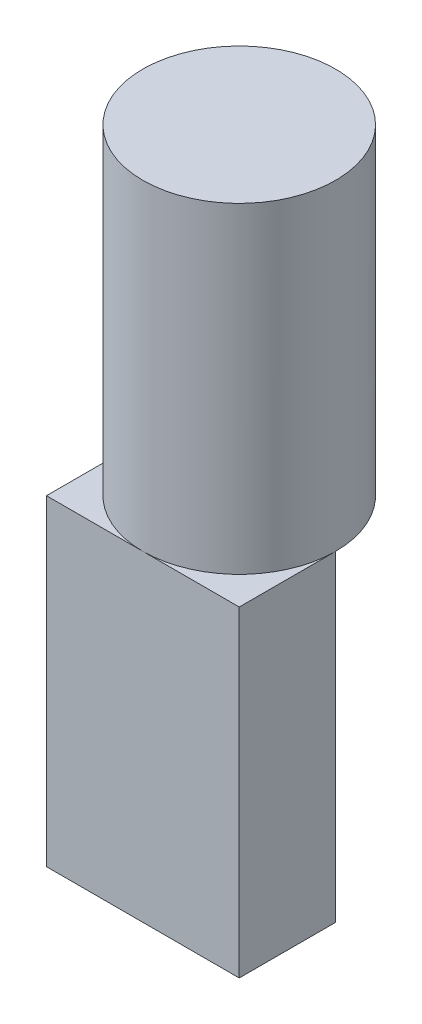
from build123d import *

# Parameters (mm, degrees)
ESBO_O1_R                = 3
RESSALTO_EXTRUS_O1_DEPTH = 10
ESBO_O2_W                = 6
ESBO_O2_H                = 3
RESSALTO_EXTRUS_O2_DEPTH = 10


with BuildPart() as part:
    # Esboço1 → Ressalto-extrusão1 (new body)
    with BuildSketch(Plane(origin=(0, 0, 0), x_dir=(1, 0, 0), z_dir=(0, 1, 0))):
        Circle(ESBO_O1_R)
    extrude(amount=RESSALTO_EXTRUS_O1_DEPTH)

    # Esboço2 → Ressalto-extrusão2 (add)
    with BuildSketch(Plane.XZ):
        with Locations((0, 1.5)):
            Rectangle(ESBO_O2_W, ESBO_O2_H)
    extrude(amount=RESSALTO_EXTRUS_O2_DEPTH)


solid = part.part
